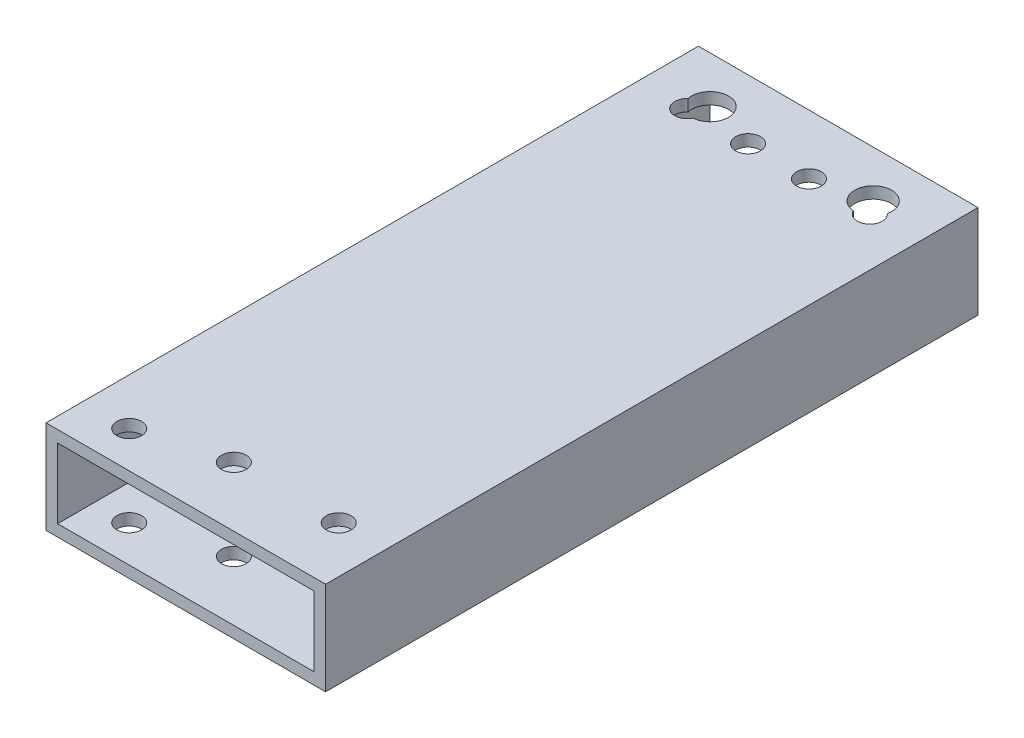
from build123d import *

# Parameters (mm, degrees)
SKETCH1_W           = 76.2
SKETCH1_H           = 25.4
SKETCH1_W_2         = 69.85
SKETCH1_H_2         = 19.05
BOSS_EXTRUDE1_DEPTH = 177.8
SKETCH4_R           = 3.3782
CUT_EXTRUDE1_DEPTH  = 26.4
SKETCH5_R           = 3.3782
CUT_EXTRUDE2_DEPTH  = 26.4
SKETCH6_R           = 3.3782
CUT_EXTRUDE3_DEPTH  = 26.4
SKETCH7_R           = 5.0419
CUT_EXTRUDE4_DEPTH  = 26.4


with BuildPart() as part:
    # Sketch1 → Boss-Extrude1 (new body)
    with BuildSketch(Plane.XY):
        with Locations((38.1, 12.7)):
            Rectangle(SKETCH1_W, SKETCH1_H)
        with Locations((38.1, 12.7)):
            Rectangle(SKETCH1_W_2, SKETCH1_H_2, mode=Mode.SUBTRACT)
    extrude(amount=BOSS_EXTRUDE1_DEPTH)

    # Sketch4 → Cut-Extrude1 (cut, through all)
    with BuildSketch(Plane(origin=(0, 25.4, 0), x_dir=(1, 0, 0), z_dir=(0, 1, 0))):
        with Locations((13.21308, -16.2687)):
            Circle(SKETCH4_R)
        with Locations((29.80436, -16.2687)):
            Circle(SKETCH4_R)
        with Locations((46.39564, -16.2687)):
            Circle(SKETCH4_R)
        with Locations((62.98692, -16.2687)):
            Circle(SKETCH4_R)
    extrude(amount=-CUT_EXTRUDE1_DEPTH, mode=Mode.SUBTRACT)

    # Sketch5 → Cut-Extrude2 (cut, through all)
    with BuildSketch(Plane.XZ):
        with Locations((12.7, 167.819500474)):
            Circle(SKETCH5_R)
    extrude(amount=-CUT_EXTRUDE2_DEPTH, mode=Mode.SUBTRACT)

    # Sketch6 → Cut-Extrude3 (cut, through all)
    with BuildSketch(Plane(origin=(0, 25.4, 0), x_dir=(1, 0, 0), z_dir=(0, 1, 0))):
        with Locations((63.5, -161.5313)):
            Circle(SKETCH6_R)
        with Locations((34.925, -161.5313)):
            Circle(SKETCH6_R)
    extrude(amount=-CUT_EXTRUDE3_DEPTH, mode=Mode.SUBTRACT)

    # Sketch7 → Cut-Extrude4 (cut, through all)
    with BuildSketch(Plane.XZ):
        with Locations((15.875, 12.7)):
            Circle(SKETCH7_R)
        with Locations((60.325, 12.7)):
            Circle(SKETCH7_R)
    extrude(amount=-CUT_EXTRUDE4_DEPTH, mode=Mode.SUBTRACT)


solid = part.part
